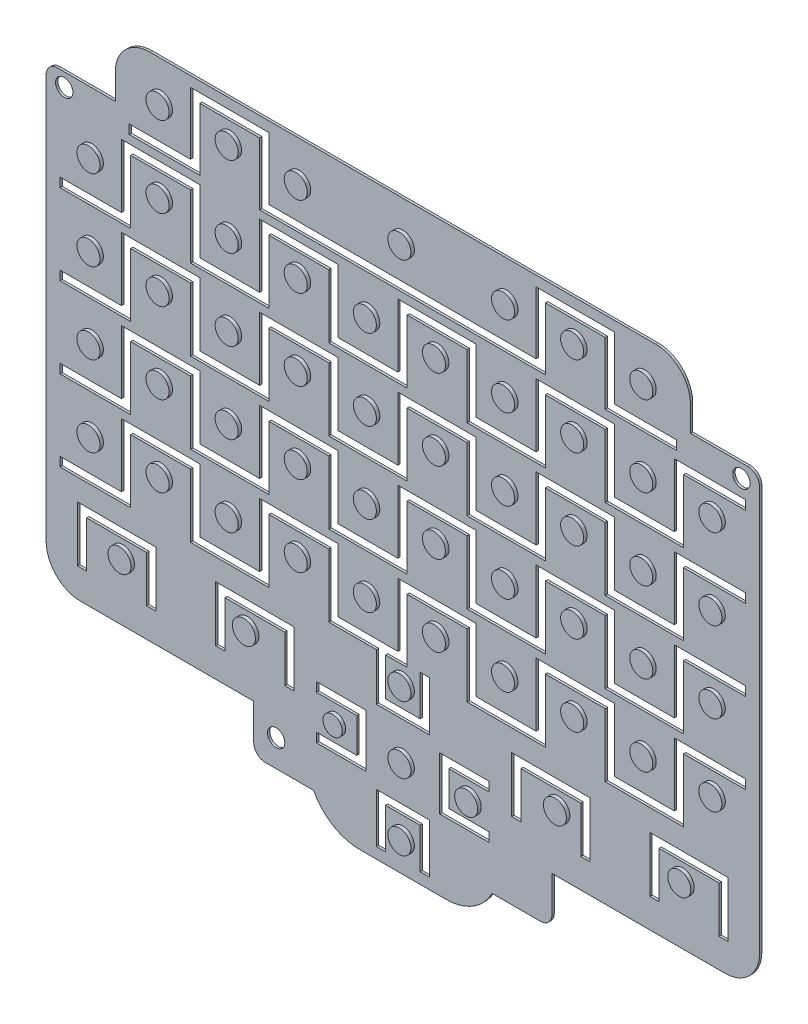
from build123d import *

# Parameters (mm, degrees)
SKETCH1_R                    = 0.75
BOSS_EXTRUDE1_DEPTH          = 0.2
CUT_EXTRUDE_THIN2_DEPTH      = 0.2
CUT_EXTRUDE_THIN3_DEPTH      = 1
CUT_EXTRUDE_THIN3_DEPTH_BACK = 0.2
CUT_EXTRUDE_THIN4_DEPTH      = 0.2
CUT_EXTRUDE_THIN5_DEPTH      = 0.2
SKETCH8_R                    = 1
SKETCH8_R_2                  = 0.836440419
BOSS_EXTRUDE2_DEPTH          = 0.3


with BuildPart() as part:
    # Sketch1 → Boss-Extrude1 (new body)
    with BuildSketch(Plane.XY):
        with BuildLine():
            Line((5.531493618, 6.79444412), (0.531493618, 6.79444412))
            ThreePointArc((0.531493618, 6.79444412), (-0.175613163, 6.501550901), (-0.468506382, 5.79444412))
            Line((-0.468506382, 5.79444412), (-0.468506382, -29.311352069))
            ThreePointArc((-0.468506382, -29.311352069), (0.410173275, -31.432672412), (2.531493618, -32.311352069))
            Line((2.531493618, -32.311352069), (17.552169293, -32.311352069))
            Line((17.552169293, -32.311352069), (17.552169293, -35.411352069))
            ThreePointArc((17.552169293, -35.411352069), (17.845062511, -36.11845885), (18.552169293, -36.411352069))
            Line((18.552169293, -36.411352069), (22.752169293, -36.411352069))
            ThreePointArc((22.752169293, -36.411352069), (24.410278739, -38.201337746), (26.758855264, -38.862823931))
            Line((26.758855264, -38.862823931), (34.242539596, -38.862823931))
            ThreePointArc((34.242539596, -38.862823931), (36.591116121, -38.201337746), (38.249225567, -36.411352069))
            Line((38.249225567, -36.411352069), (42.449225567, -36.411352069))
            ThreePointArc((42.449225567, -36.411352069), (43.156332349, -36.11845885), (43.449225567, -35.411352069))
            Line((43.449225567, -35.411352069), (43.449225567, -32.311352069))
            Line((43.449225567, -32.311352069), (58.469901242, -32.311352069))
            ThreePointArc((58.469901242, -32.311352069), (60.591221585, -31.432672412), (61.469901242, -29.311352069))
            Line((61.469901242, -29.311352069), (61.469901242, 5.79444412))
            ThreePointArc((61.469901242, 5.79444412), (61.177008023, 6.501550901), (60.469901242, 6.79444412))
            Line((60.469901242, 6.79444412), (55.469901242, 6.79444412))
            Line((55.469901242, 6.79444412), (55.469901242, 8.994219453))
            ThreePointArc((55.469901242, 8.994219453), (54.591221585, 11.115539797), (52.469901242, 11.994219453))
            Line((52.469901242, 11.994219453), (8.531493618, 11.994219453))
            ThreePointArc((8.531493618, 11.994219453), (6.410173275, 11.115539797), (5.531493618, 8.994219453))
            Line((5.531493618, 8.994219453), (5.531493618, 6.79444412))
        make_face()
        with Locations((19.500758038, -34.082908404)):
            Circle(SKETCH1_R, mode=Mode.SUBTRACT)
        with Locations((1.100758038, 5.617091596)):
            Circle(SKETCH1_R, mode=Mode.SUBTRACT)
        with Locations((59.900758038, 5.617091596)):
            Circle(SKETCH1_R, mode=Mode.SUBTRACT)
    extrude(amount=BOSS_EXTRUDE1_DEPTH)

    # Sketch2 → Cut-Extrude-Thin2 (cut)
    with BuildSketch(Plane.XY.offset(0.2)):
        Polygon((60.269901242, -16.80555588), (54.069901242, -16.80555588), (54.069901242, -22.30555588), (48.869901242, -22.30555588), (48.869901242, -16.80555588), (42.069901242, -16.80555588), (42.069901242, -22.30555588), (36.869901242, -22.30555588), (36.869901242, -16.80555588), (30.069901242, -16.80555588), (30.069901242, -22.30555588), (24.869901242, -22.30555588), (24.869901242, -16.80555588), (18.069901242, -16.80555588), (18.069901242, -22.30555588), (12.869901242, -22.30555588), (12.869901242, -16.805705658), (6.069901242, -16.805705658), (6.069901242, -22.30555588), (0.731493618, -22.30555588), (0.731493618, -23.10555588), (6.869901242, -23.10555588), (6.869901242, -17.605705658), (12.069901242, -17.605705658), (12.069901242, -23.10555588), (18.869901242, -23.10555588), (18.869901242, -17.60555588), (24.069901242, -17.60555588), (24.069901242, -23.10555588), (30.869901242, -23.10555588), (30.869901242, -17.60555588), (36.069901242, -17.60555588), (36.069901242, -23.10555588), (42.869901242, -23.10555588), (42.869901242, -17.60555588), (48.069901242, -17.60555588), (48.069901242, -23.10555588), (54.869901242, -23.10555588), (54.869901242, -17.60555588), (60.269901242, -17.60555588), align=None)
        Polygon((60.269901242, -9.80555588), (54.069901242, -9.80555588), (54.069901242, -15.30555588), (48.869901242, -15.30555588), (48.869901242, -9.80555588), (42.069901242, -9.80555588), (42.069901242, -15.30555588), (36.869901242, -15.30555588), (36.869901242, -9.80555588), (30.069901242, -9.80555588), (30.069901242, -15.30555588), (24.869901242, -15.30555588), (24.869901242, -9.80555588), (18.069901242, -9.80555588), (18.069901242, -15.30555588), (12.869901242, -15.30555588), (12.869901242, -9.805705658), (6.069901242, -9.805705658), (6.069901242, -15.30555588), (0.731493618, -15.30555588), (0.731493618, -16.10555588), (6.869901242, -16.10555588), (6.869901242, -10.605705658), (12.069901242, -10.605705658), (12.069901242, -16.10555588), (18.869901242, -16.10555588), (18.869901242, -10.60555588), (24.069901242, -10.60555588), (24.069901242, -16.10555588), (30.869901242, -16.10555588), (30.869901242, -10.60555588), (36.069901242, -10.60555588), (36.069901242, -16.10555588), (42.869901242, -16.10555588), (42.869901242, -10.60555588), (48.069901242, -10.60555588), (48.069901242, -16.10555588), (54.869901242, -16.10555588), (54.869901242, -10.60555588), (60.269901242, -10.60555588), align=None)
        Polygon((60.269901242, -2.80555588), (54.069901242, -2.80555588), (54.069901242, -8.30555588), (48.869901242, -8.30555588), (48.869901242, -2.80555588), (42.069901242, -2.80555588), (42.069901242, -8.30555588), (36.869901242, -8.30555588), (36.869901242, -2.80555588), (30.069901242, -2.80555588), (30.069901242, -8.30555588), (24.869901242, -8.30555588), (24.869901242, -2.80555588), (18.069901242, -2.80555588), (18.069901242, -8.30555588), (12.869901242, -8.30555588), (12.869901242, -2.805705658), (6.069901242, -2.805705658), (6.069901242, -8.30555588), (0.731493618, -8.30555588), (0.731493618, -9.10555588), (6.869901242, -9.10555588), (6.869901242, -3.605705658), (12.069901242, -3.605705658), (12.069901242, -9.10555588), (18.869901242, -9.10555588), (18.869901242, -3.60555588), (24.069901242, -3.60555588), (24.069901242, -9.10555588), (30.869901242, -9.10555588), (30.869901242, -3.60555588), (36.069901242, -3.60555588), (36.069901242, -9.10555588), (42.869901242, -9.10555588), (42.869901242, -3.60555588), (48.069901242, -3.60555588), (48.069901242, -9.10555588), (54.869901242, -9.10555588), (54.869901242, -3.60555588), (60.269901242, -3.60555588), align=None)
        Polygon((60.269901242, 4.19444412), (54.069901242, 4.19444412), (54.069901242, -1.30555588), (48.869901242, -1.30555588), (48.869901242, 4.19444412), (42.069901242, 4.19444412), (42.069901242, -1.30555588), (36.869901242, -1.30555588), (36.869901242, 4.19444412), (30.069901242, 4.19444412), (30.069901242, -1.30555588), (24.869901242, -1.30555588), (24.869901242, 4.19444412), (18.069901242, 4.19444412), (18.069901242, -1.30555588), (12.869901242, -1.30555588), (12.869901242, 4.194294342), (6.069901242, 4.194294342), (6.069901242, -1.30555588), (0.731493618, -1.30555588), (0.731493618, -2.10555588), (6.869901242, -2.10555588), (6.869901242, 3.394294342), (12.069901242, 3.394294342), (12.069901242, -2.10555588), (18.869901242, -2.10555588), (18.869901242, 3.39444412), (24.069901242, 3.39444412), (24.069901242, -2.10555588), (30.869901242, -2.10555588), (30.869901242, 3.39444412), (36.069901242, 3.39444412), (36.069901242, -2.10555588), (42.869901242, -2.10555588), (42.869901242, 3.39444412), (48.069901242, 3.39444412), (48.069901242, -2.10555588), (54.869901242, -2.10555588), (54.869901242, 3.39444412), (60.269901242, 3.39444412), align=None)
    extrude(amount=-CUT_EXTRUDE_THIN2_DEPTH, mode=Mode.SUBTRACT)

    # Sketch3 → Cut-Extrude-Thin3 (cut, two sides)
    with BuildSketch(Plane.XY.offset(0.2)) as cut_extrude_thin3_sk:
        Polygon((54.269901242, 5.69444412), (48.869901242, 5.69444412), (48.869901242, 11.105846341), (42.069901242, 11.105846341), (42.069901242, 5.69444412), (18.869901242, 5.69444412), (18.869901242, 11.105846341), (12.069901242, 11.105846341), (12.069901242, 5.69444412), (6.731493618, 5.69444412), (6.731493618, 4.89444412), (12.869901242, 4.89444412), (12.869901242, 10.305846341), (18.069901242, 10.305846341), (18.069901242, 4.89444412), (42.869901242, 4.89444412), (42.869901242, 10.305846341), (48.069901242, 10.305846341), (48.069901242, 4.89444412), (54.269901242, 4.89444412), align=None)
    extrude(amount=CUT_EXTRUDE_THIN3_DEPTH, mode=Mode.SUBTRACT)
    extrude(cut_extrude_thin3_sk.sketch, amount=-CUT_EXTRUDE_THIN3_DEPTH_BACK, mode=Mode.SUBTRACT)

    # Sketch4 → Cut-Extrude-Thin4 (cut)
    with BuildSketch(Plane.XY.offset(0.2)):
        Polygon((58.75069743, -29.789324271), (58.75069743, -24.975421762), (51.95069743, -24.975421762), (51.95069743, -29.789324271), (52.75069743, -29.789324271), (52.75069743, -25.775421762), (57.95069743, -25.775421762), (57.95069743, -29.789324271), align=None)
        Polygon((46.75069743, -29.789324271), (46.75069743, -24.975421762), (39.95069743, -24.975421762), (39.95069743, -29.789324271), (40.75069743, -29.789324271), (40.75069743, -25.775421762), (45.95069743, -25.775421762), (45.95069743, -29.789324271), align=None)
        Polygon((15.05069743, -29.789324271), (15.05069743, -25.775421762), (20.25069743, -25.775421762), (20.25069743, -29.789324271), (21.05069743, -29.789324271), (21.05069743, -24.975421762), (14.25069743, -24.975421762), (14.25069743, -29.789324271), align=None)
        Polygon((3.05069743, -29.789324271), (3.05069743, -25.775421762), (8.25069743, -25.775421762), (8.25069743, -29.789324271), (9.05069743, -29.789324271), (9.05069743, -24.975421762), (2.25069743, -24.975421762), (2.25069743, -29.789324271), align=None)
    extrude(amount=-CUT_EXTRUDE_THIN4_DEPTH, mode=Mode.SUBTRACT)

    # Sketch5 → Cut-Extrude-Thin5 (cut)
    with BuildSketch(Plane.XY.offset(0.2)):
        Polygon((32.00069743, -37.912823931), (32.00069743, -34.412823931), (29.00069743, -34.412823931), (29.00069743, -37.912823931), (28.20069743, -37.912823931), (28.20069743, -33.612823931), (32.80069743, -33.612823931), (32.80069743, -37.912823931), align=None)
        Polygon((23.00069743, -31.912823931), (26.50069743, -31.912823931), (26.50069743, -28.912823931), (23.00069743, -28.912823931), (23.00069743, -28.112823931), (27.30069743, -28.112823931), (27.30069743, -32.712823931), (23.00069743, -32.712823931), align=None)
        Polygon((29.00069743, -22.912823931), (29.00069743, -26.412823931), (32.00069743, -26.412823931), (32.00069743, -22.912823931), (32.80069743, -22.912823931), (32.80069743, -27.212823931), (28.20069743, -27.212823931), (28.20069743, -22.912823931), align=None)
        Polygon((38.00069743, -28.912823931), (34.50069743, -28.912823931), (34.50069743, -31.912823931), (38.00069743, -31.912823931), (38.00069743, -32.712823931), (33.70069743, -32.712823931), (33.70069743, -28.112823931), (38.00069743, -28.112823931), align=None)
    extrude(amount=-CUT_EXTRUDE_THIN5_DEPTH, mode=Mode.SUBTRACT)

    # Sketch8 → Boss-Extrude2 (add)
    with BuildSketch(Plane.XY.offset(0.2)):
        with Locations((54.800693614, -27.21282598)):
            Circle(SKETCH8_R)
        with Locations((44.000698192, -27.212826134)):
            Circle(SKETCH8_R)
        with Locations((36.30069366, -30.412823192)):
            Circle(SKETCH8_R)
        with Locations((30.500698238, -30.412823274)):
            Circle(SKETCH8_R)
        with Locations((30.500698155, -24.612827852)):
            Circle(SKETCH8_R)
        with Locations((30.50069832, -36.212826326)):
            Circle(SKETCH8_R)
        with Locations((24.700695186, -30.412823357)):
            Circle(SKETCH8_R_2)
        with Locations((17.000690563, -27.212826519)):
            Circle(SKETCH8_R)
        with Locations((6.20069514, -27.212826672)):
            Circle(SKETCH8_R)
        with Locations((51.500690053, 8.58717321)):
            Circle(SKETCH8_R)
        with Locations((45.500690053, 8.587173125)):
            Circle(SKETCH8_R)
        with Locations((39.500697682, 8.587173039)):
            Circle(SKETCH8_R)
        with Locations((30.500697682, 8.587172911)):
            Circle(SKETCH8_R)
        with Locations((21.500697682, 8.587172783)):
            Circle(SKETCH8_R)
        with Locations((15.500690053, 8.587172697)):
            Circle(SKETCH8_R)
        with Locations((9.500690053, 8.587172612)):
            Circle(SKETCH8_R)
        with Locations((57.500690452, -19.412830519)):
            Circle(SKETCH8_R)
        with Locations((51.500690452, -19.412830519)):
            Circle(SKETCH8_R)
        with Locations((45.500690452, -19.412830519)):
            Circle(SKETCH8_R)
        with Locations((39.500690452, -19.412830519)):
            Circle(SKETCH8_R)
        with Locations((33.500690452, -19.412830519)):
            Circle(SKETCH8_R)
        with Locations((27.500690452, -19.412830519)):
            Circle(SKETCH8_R)
        with Locations((21.500690452, -19.412830519)):
            Circle(SKETCH8_R)
        with Locations((15.500690452, -19.412830519)):
            Circle(SKETCH8_R)
        with Locations((9.500690452, -19.412830519)):
            Circle(SKETCH8_R)
        with Locations((3.500690452, -19.412830519)):
            Circle(SKETCH8_R)
        with Locations((51.500690452, -12.412830519)):
            Circle(SKETCH8_R)
        with Locations((45.500690452, -12.412830519)):
            Circle(SKETCH8_R)
        with Locations((39.500690452, -12.412830519)):
            Circle(SKETCH8_R)
        with Locations((33.500690452, -12.412830519)):
            Circle(SKETCH8_R)
        with Locations((27.500690452, -12.412830519)):
            Circle(SKETCH8_R)
        with Locations((21.500690452, -12.412830519)):
            Circle(SKETCH8_R)
        with Locations((15.500690452, -12.412830519)):
            Circle(SKETCH8_R)
        with Locations((9.500690452, -12.412830519)):
            Circle(SKETCH8_R)
        with Locations((3.500690452, -12.412830519)):
            Circle(SKETCH8_R)
        with Locations((51.500690452, -5.412830519)):
            Circle(SKETCH8_R)
        with Locations((45.500690452, -5.412830519)):
            Circle(SKETCH8_R)
        with Locations((39.500690452, -5.412830519)):
            Circle(SKETCH8_R)
        with Locations((33.500690452, -5.412830519)):
            Circle(SKETCH8_R)
        with Locations((27.500690452, -5.412830519)):
            Circle(SKETCH8_R)
        with Locations((21.500690452, -5.412830519)):
            Circle(SKETCH8_R)
        with Locations((15.500690452, -5.412830519)):
            Circle(SKETCH8_R)
        with Locations((9.500690452, -5.412830519)):
            Circle(SKETCH8_R)
        with Locations((3.500690452, -5.412830519)):
            Circle(SKETCH8_R)
        with Locations((51.500690452, 1.587169481)):
            Circle(SKETCH8_R)
        with Locations((45.500690452, 1.587169481)):
            Circle(SKETCH8_R)
        with Locations((39.500690452, 1.587169481)):
            Circle(SKETCH8_R)
        with Locations((33.500690452, 1.587169481)):
            Circle(SKETCH8_R)
        with Locations((27.500690452, 1.587169481)):
            Circle(SKETCH8_R)
        with Locations((21.500690452, 1.587169481)):
            Circle(SKETCH8_R)
        with Locations((15.500690452, 1.587169481)):
            Circle(SKETCH8_R)
        with Locations((9.500690452, 1.587169481)):
            Circle(SKETCH8_R)
        with Locations((3.500690452, 1.587169481)):
            Circle(SKETCH8_R)
        with Locations((57.500690452, -12.412830519)):
            Circle(SKETCH8_R)
        with Locations((57.500690452, -5.412830519)):
            Circle(SKETCH8_R)
        with Locations((57.500690452, 1.587169481)):
            Circle(SKETCH8_R)
    extrude(amount=BOSS_EXTRUDE2_DEPTH)


solid = part.part
